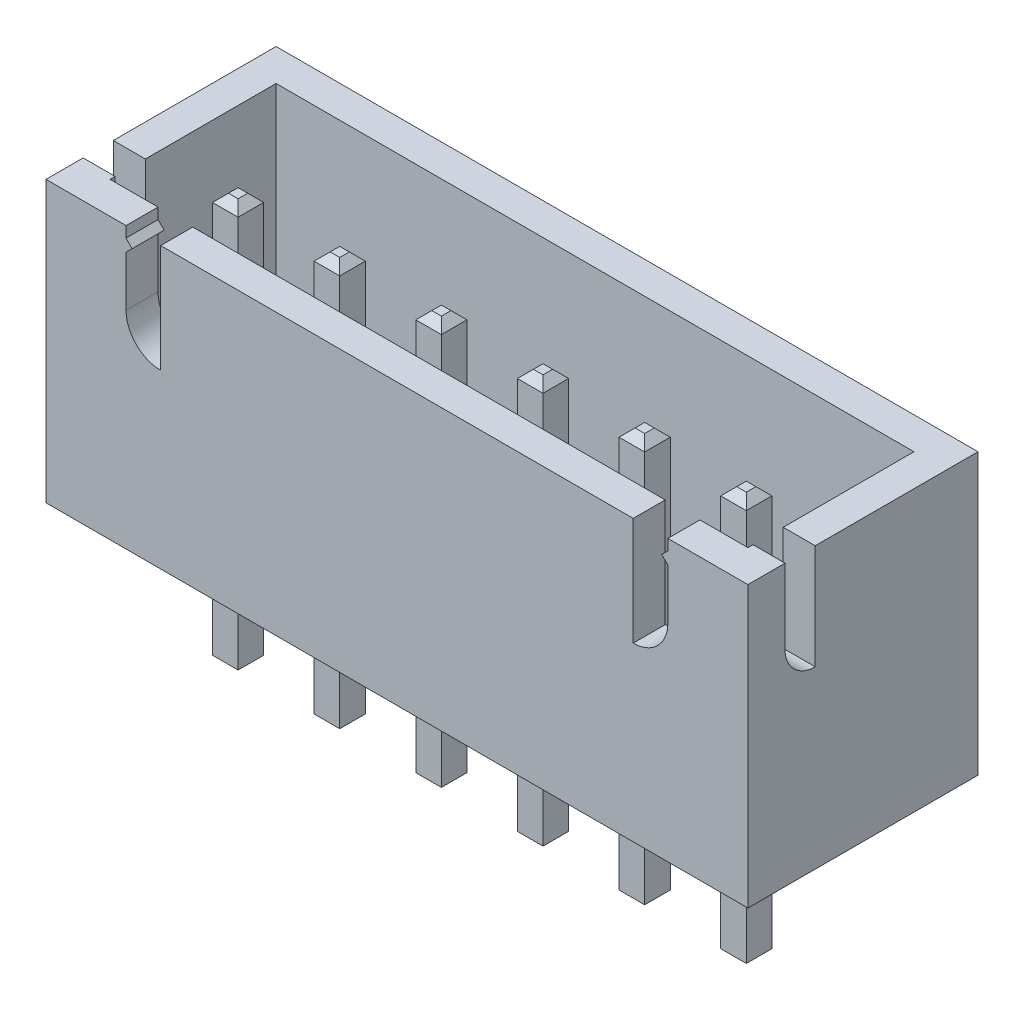
from build123d import *

# Parameters (mm, degrees)
SKETCH1_W                = 17.54
SKETCH1_H                = 5.75
BOSS_EXTRUDE1_DEPTH      = 7
SHELL1_T                 = -0.8
CUT_EXTRUDE1_DEPTH       = 18.54
CUT_EXTRUDE2_REACH       = 7.75
SKETCH4_W                = 0.64
SKETCH4_H                = 0.64
BOSS_EXTRUDE2_DEPTH      = 3.45
BOSS_EXTRUDE2_DEPTH_BACK = 6.75
CHAMFER1_SIZE            = 0.2


with BuildPart() as part:
    # Sketch1 → Boss-Extrude1 (new body)
    with BuildSketch(Plane(origin=(0, 0, 0), x_dir=(1, 0, 0), z_dir=(0, 1, 0))):
        Rectangle(SKETCH1_W, SKETCH1_H)
    extrude(amount=BOSS_EXTRUDE1_DEPTH)

    # Shell1
    shell1_openings = [part.faces().sort_by_distance(p)[0] for p in [
        (0, 7, 0),
    ]]
    offset(amount=SHELL1_T, openings=shell1_openings, kind=Kind.INTERSECTION)

    # Sketch2 → Cut-Extrude1 (cut, through all)
    with BuildSketch(Plane(origin=(8.77, 0, 0), x_dir=(0, 0, -1), z_dir=(1, 0, 0))):
        with BuildLine():
            Line((-1.19301282, 7), (-1.19301282, 4.379603984))
            ThreePointArc((-1.19301282, 4.379603984), (-1.72610374, 4.600417472), (-1.946917229, 5.133508392))
            Line((-1.946917229, 5.133508392), (-1.946917229, 7))
            Line((-1.946917229, 7), (-1.19301282, 7))
        make_face()
    extrude(amount=-CUT_EXTRUDE1_DEPTH, mode=Mode.SUBTRACT)

    # Sketch3 → Cut-Extrude2 (cut, up to next)
    with BuildSketch(Plane.XY.offset(2.875), mode=Mode.PRIVATE) as cut_extrude2_sk1:
        with BuildLine():
            Line((-6.77, 7), (-6.77, 6.728922615))
            Line((-6.77, 6.728922615), (-6.617135549, 6.576058164))
            Line((-6.617135549, 6.576058164), (-6.77, 6.423193713))
            Line((-6.77, 6.423193713), (-6.77, 5.166308225))
            ThreePointArc((-6.77, 5.166308225), (-6.516286554, 4.553789782), (-5.90376811, 4.300076336))
            Line((-5.90376811, 4.300076336), (-5.90376811, 7))
            Line((-5.90376811, 7), (-6.77, 7))
        make_face()
    cut_extrude2_tool1 = extrude(cut_extrude2_sk1.sketch, amount=-CUT_EXTRUDE2_REACH, mode=Mode.PRIVATE) & part.part
    add(cut_extrude2_tool1.solids().sort_by_distance((-6.314828, 5.726435, 2.875))[0], mode=Mode.SUBTRACT)
    # Sketch3 → Cut-Extrude2 (cut, up to next)
    with BuildSketch(Plane.XY.offset(2.875), mode=Mode.PRIVATE) as cut_extrude2_sk2:
        with BuildLine():
            Line((5.90376811, 7), (6.77, 7))
            Line((6.77, 7), (6.77, 6.728922615))
            Line((6.77, 6.728922615), (6.617135549, 6.576058164))
            Line((6.617135549, 6.576058164), (6.77, 6.423193713))
            Line((6.77, 6.423193713), (6.77, 5.166308225))
            ThreePointArc((6.77, 5.166308225), (6.516286554, 4.553789782), (5.90376811, 4.300076336))
            Line((5.90376811, 4.300076336), (5.90376811, 7))
        make_face()
    cut_extrude2_tool2 = extrude(cut_extrude2_sk2.sketch, amount=-CUT_EXTRUDE2_REACH, mode=Mode.PRIVATE) & part.part
    add(cut_extrude2_tool2.solids().sort_by_distance((6.314828, 5.726435, 2.875))[0], mode=Mode.SUBTRACT)

    # Sketch4 → Boss-Extrude2 (add, two sides)
    with BuildSketch(Plane.XZ) as boss_extrude2_sk:
        with Locations((-6.32, 0.525)):
            Rectangle(SKETCH4_W, SKETCH4_H)
        with Locations((-3.78, 0.525)):
            Rectangle(SKETCH4_W, SKETCH4_H)
        with Locations((-1.24, 0.525)):
            Rectangle(SKETCH4_W, SKETCH4_H)
        with Locations((1.3, 0.525)):
            Rectangle(SKETCH4_W, SKETCH4_H)
        with Locations((3.84, 0.525)):
            Rectangle(SKETCH4_W, SKETCH4_H)
        with Locations((6.38, 0.525)):
            Rectangle(SKETCH4_W, SKETCH4_H)
    extrude(amount=BOSS_EXTRUDE2_DEPTH)
    extrude(boss_extrude2_sk.sketch, amount=-BOSS_EXTRUDE2_DEPTH_BACK)

    # Chamfer1
    chamfer1_edges = [part.edges().sort_by_distance(p)[0] for p in [
        (-6, 6.75, 0.525),
        (-6.32, 6.75, 0.205),
        (-6.64, 6.75, 0.525),
        (-6.32, 6.75, 0.845),
        (-6, -3.45, 0.525),
        (-6.32, -3.45, 0.845),
        (-6.64, -3.45, 0.525),
        (-6.32, -3.45, 0.205),
        (-3.78, 6.75, 0.205),
        (-4.1, 6.75, 0.525),
        (-3.78, 6.75, 0.845),
        (-3.46, 6.75, 0.525),
        (-3.78, -3.45, 0.205),
        (-3.46, -3.45, 0.525),
        (-3.78, -3.45, 0.845),
        (-4.1, -3.45, 0.525),
        (-1.24, 6.75, 0.205),
        (-1.56, 6.75, 0.525),
        (-1.24, 6.75, 0.845),
        (-0.92, 6.75, 0.525),
        (-1.24, -3.45, 0.205),
        (-0.92, -3.45, 0.525),
        (-1.24, -3.45, 0.845),
        (-1.56, -3.45, 0.525),
        (1.3, 6.75, 0.205),
        (0.98, 6.75, 0.525),
        (1.3, 6.75, 0.845),
        (1.62, 6.75, 0.525),
        (1.3, -3.45, 0.205),
        (1.62, -3.45, 0.525),
        (1.3, -3.45, 0.845),
        (0.98, -3.45, 0.525),
        (3.84, 6.75, 0.205),
        (3.52, 6.75, 0.525),
        (3.84, 6.75, 0.845),
        (4.16, 6.75, 0.525),
        (3.84, -3.45, 0.205),
        (4.16, -3.45, 0.525),
        (3.84, -3.45, 0.845),
        (3.52, -3.45, 0.525),
        (6.38, 6.75, 0.205),
        (6.06, 6.75, 0.525),
        (6.38, 6.75, 0.845),
        (6.7, 6.75, 0.525),
        (6.38, -3.45, 0.205),
        (6.7, -3.45, 0.525),
        (6.38, -3.45, 0.845),
        (6.06, -3.45, 0.525),
    ]]
    chamfer(chamfer1_edges, length=CHAMFER1_SIZE)


solid = part.part
